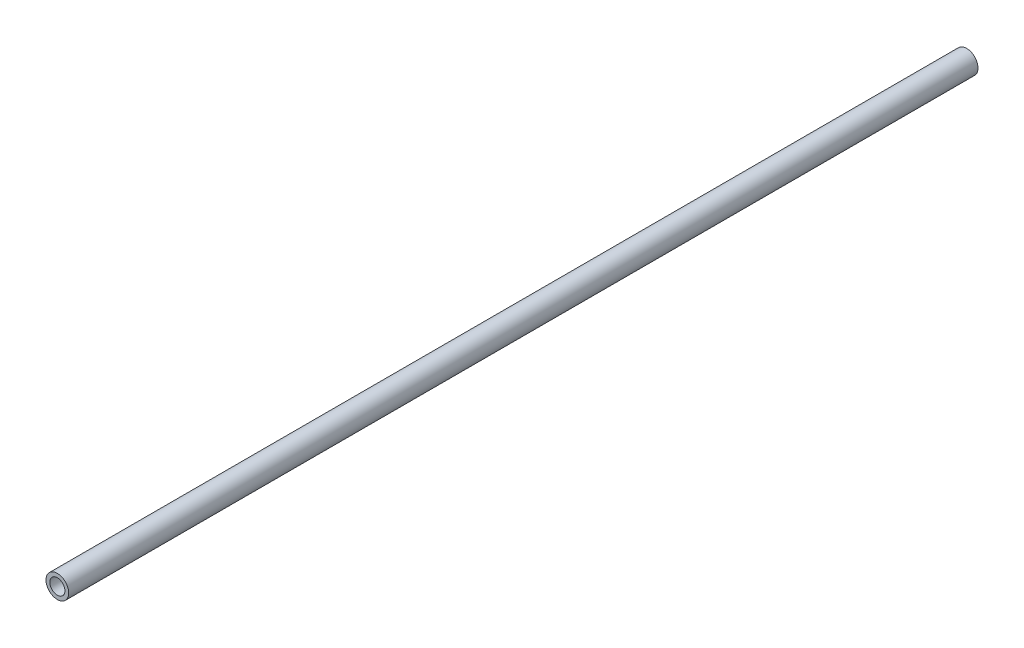
from build123d import *

# Parameters (mm, degrees)
SKETCH2_R           = 7.62
SKETCH2_R_2         = 5.08
BOSS_EXTRUDE1_DEPTH = 609.6


with BuildPart() as part:
    # Sketch2 → Boss-Extrude1 (new body)
    with BuildSketch(Plane.XY):
        Circle(SKETCH2_R)
        Circle(SKETCH2_R_2, mode=Mode.SUBTRACT)
    extrude(amount=BOSS_EXTRUDE1_DEPTH)


solid = part.part
